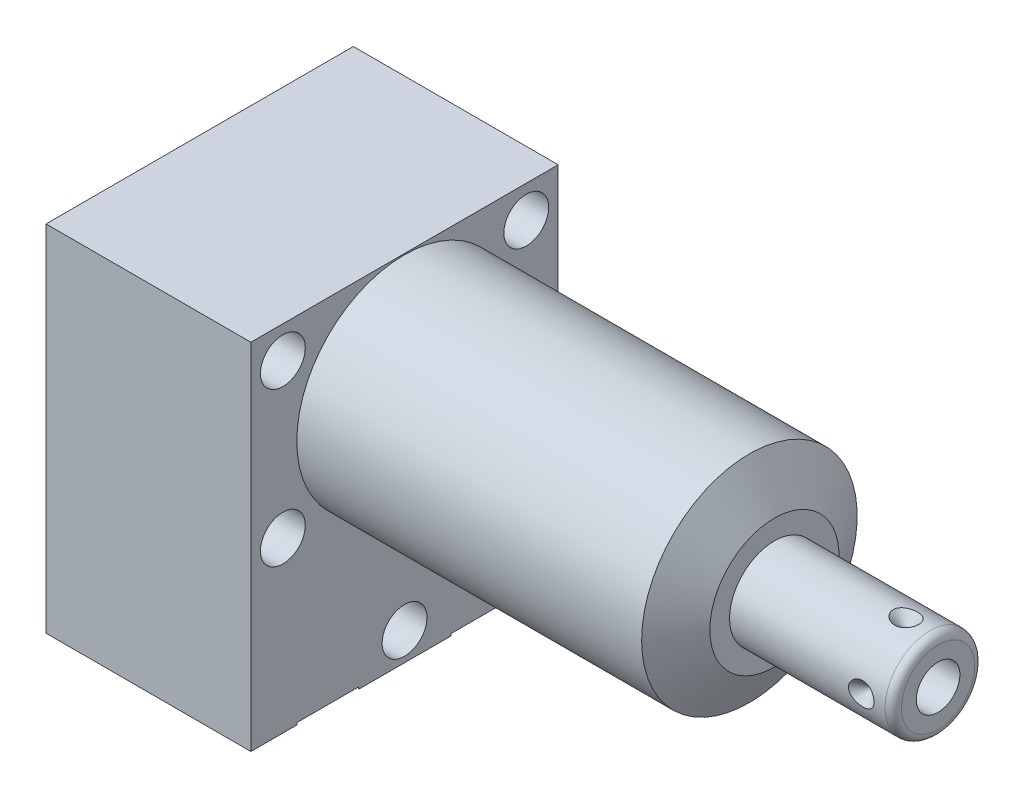
from build123d import *

# Parameters (mm, degrees)
SKETCH1_W           = 38.1
SKETCH1_H           = 43.942
EXTRUDE1_DEPTH      = 45.847
EXTRUDE1_DEPTH_BACK = 25.4
CUT_EXTRUDE1_REACH  = 47.847
SKETCH2_W           = 38.1
SKETCH2_H           = 43.942
SKETCH2_R           = 13.3604
SKETCH14_R          = 7.9375
CUT_EXTRUDE2_DEPTH  = 2.667
SKETCH10_R          = 6.4389
EXTRUDE2_DEPTH      = 1.651
SKETCH11_R          = 4.8006
EXTRUDE3_DEPTH      = 2.667
CIRPATTERN1_COUNT   = 4
HOLE1_D             = 5.5626
HOLE1_DEPTH         = 25.4


with BuildPart() as part:
    # Sketch1 → Extrude1 (new body, two sides)
    with BuildSketch(Plane(origin=(0, 0, 0), x_dir=(0, 0, -1), z_dir=(1, 0, 0))) as extrude1_sk:
        with Locations((0, -8.4836)):
            Rectangle(SKETCH1_W, SKETCH1_H)
    extrude(amount=EXTRUDE1_DEPTH)
    extrude(extrude1_sk.sketch, amount=-EXTRUDE1_DEPTH_BACK)

    # Sketch2 → Cut-Extrude1 (cut, up to next)
    with BuildSketch(Plane(origin=(0, 0, 0), x_dir=(0, 0, -1), z_dir=(1, 0, 0)), mode=Mode.PRIVATE) as cut_extrude1_sk1:
        with Locations((0, -8.4836)):
            Rectangle(SKETCH2_W, SKETCH2_H)
        Circle(SKETCH2_R, mode=Mode.SUBTRACT)
    cut_extrude1_tool1 = extrude(cut_extrude1_sk1.sketch, amount=CUT_EXTRUDE1_REACH, mode=Mode.PRIVATE) & part.part
    add(cut_extrude1_tool1.solids().sort_by_distance((0, 13.429241, 0))[0], mode=Mode.SUBTRACT)

    # Sketch3 → Cut-Revolve1 (revolve, cut)
    with BuildSketch(Plane.XY, mode=Mode.PRIVATE) as cut_revolve1_sk:
        Polygon((42.752748967, 13.3604), (45.847, 8.001), (45.847, 13.3604), align=None)
    revolve(cut_revolve1_sk.sketch.rotate(Axis((42.598036416, 0, 0), (1, 0, 0)), 90), axis=Axis((42.598036416, 0, 0), (1, 0, 0)), mode=Mode.SUBTRACT)  # turned: the seam where the file's is

    # S2D0002 → Cut-Revolve2 (revolve, cut)
    with BuildSketch(Plane(origin=(-22.733, -19.8374, 9.525), x_dir=(0, 1, 0), z_dir=(0, 0, 1)), mode=Mode.PRIVATE) as cut_revolve2_sk:
        Polygon((-0.8128, 0), (3.7338, 0), (3.293786662, -2.0701), (2.6416, -2.722286662), (2.6416, -13.97), (-0.8128, -13.97), align=None)
    revolve(cut_revolve2_sk.sketch.rotate(Axis((-8.0645, -20.6502, 9.525), (-1, 0, 0)), 90), axis=Axis((-8.0645, -20.6502, 9.525), (-1, 0, 0)), mode=Mode.SUBTRACT)  # turned: the seam where the file's is

    # Sketch5 → Cut-Revolve3 (revolve, cut)
    with BuildSketch(Plane(origin=(-22.733, -19.8374, -9.525), x_dir=(0, 1, 0), z_dir=(0, 0, 1)), mode=Mode.PRIVATE) as cut_revolve3_sk:
        Polygon((-0.8128, 0), (3.7338, 0), (3.293786662, -2.0701), (2.6416, -2.722286662), (2.6416, -13.97), (-0.8128, -13.97), align=None)
    revolve(cut_revolve3_sk.sketch.rotate(Axis((-8.0645, -20.6502, -9.525), (-1, 0, 0)), 90), axis=Axis((-8.0645, -20.6502, -9.525), (-1, 0, 0)), mode=Mode.SUBTRACT)  # turned: the seam where the file's is

    # Sketch14 → Cut-Extrude2 (cut)
    with BuildSketch(Plane.ZY.offset(25.4)):
        with Locations((-9.525, -20.6502)):
            Circle(SKETCH14_R)
        with Locations((9.525, -20.6502)):
            Circle(SKETCH14_R)
    extrude(amount=-CUT_EXTRUDE2_DEPTH, mode=Mode.SUBTRACT)

    # Sketch6 → Cut-Revolve4 (revolve, cut)
    with BuildSketch(Plane(origin=(-8.7376, -30.2006, 9.525), x_dir=(-1, 0, 0), z_dir=(0, 0, 1)), mode=Mode.PRIVATE) as cut_revolve4_sk:
        Polygon((6.18363, 0), (5.641036865, -2.5527), (4.97713, -3.216606865), (4.97713, -17.272), (0, -17.272), (0, 0), (0, 0.254), (9.52373, 0.254), (9.52373, 0), align=None)
    revolve(cut_revolve4_sk.sketch.rotate(Axis((-8.7376, -12.065, 9.525), (0, -1, 0)), 270), axis=Axis((-8.7376, -12.065, 9.525), (0, -1, 0)), mode=Mode.SUBTRACT)  # turned: the seam where the file's is

    # Sketch7 → Cut-Revolve5 (revolve, cut)
    with BuildSketch(Plane(origin=(-8.7376, -30.2006, -9.525), x_dir=(-1, 0, 0), z_dir=(0, 0, 1)), mode=Mode.PRIVATE) as cut_revolve5_sk:
        Polygon((6.1849, 0), (5.642306865, -2.5527), (4.9784, -3.216606865), (4.9784, -17.272), (0, -17.272), (0, 0), (0, 0.254), (9.52373, 0.254), (9.52373, 0), align=None)
    revolve(cut_revolve5_sk.sketch.rotate(Axis((-8.7376, -12.065, -9.525), (0, -1, 0)), 270), axis=Axis((-8.7376, -12.065, -9.525), (0, -1, 0)), mode=Mode.SUBTRACT)  # turned: the seam where the file's is

    # Sketch8 → Revolve1 (revolve)
    with BuildSketch(Plane.XY, mode=Mode.PRIVATE) as revolve1_sk:
        with BuildLine():
            Line((45.847, 0), (45.847, 5.55625))
            Line((45.847, 5.55625), (65.1256, 5.55625))
            ThreePointArc((65.1256, 5.55625), (65.84402049, 5.25867049), (66.1416, 4.54025))
            Line((66.1416, 4.54025), (66.1416, 0))
            Line((66.1416, 0), (45.847, 0))
        make_face()
    revolve(revolve1_sk.sketch.rotate(Axis((44.83227, 0, 0), (1, 0, 0)), 90), axis=Axis((44.83227, 0, 0), (1, 0, 0)))  # turned: the seam where the file's is

    # S2D0001 → Cut-Revolve6 (revolve, cut)
    with BuildSketch(Plane(origin=(66.1416, -2.8067, 0), x_dir=(0, -1, 0), z_dir=(0, 0, 1)), mode=Mode.PRIVATE) as cut_revolve6_sk:
        Polygon((-0.1016, 0), (-0.1016, -9.652), (-2.8067, -11.277388061), (-2.8067, 0), align=None)
    revolve(cut_revolve6_sk.sketch.rotate(Axis((53.702842726, 0, 0), (1, 0, 0)), 270), axis=Axis((53.702842726, 0, 0), (1, 0, 0)), mode=Mode.SUBTRACT)  # turned: the seam where the file's is

    # Sketch10 → Extrude2 (add)
    with BuildSketch(Plane(origin=(-25.4, -30.2006, 0), x_dir=(0, 0, -1), z_dir=(0, -1, 0))):
        with Locations(Location((-9.525, 16.6624, 0), (0, 0, 180))):  # turned: the seam where the file's is
            Circle(SKETCH10_R)
    extrude(amount=EXTRUDE2_DEPTH)

    # Sketch11 → Extrude3 (add)
    with BuildSketch(Plane.ZY.offset(22.733)):
        with Locations(Location((9.525, -20.6502, 0), (0, 0, 180))):  # turned: the seam where the file's is
            Circle(SKETCH11_R)
    extrude(amount=EXTRUDE3_DEPTH)

    # Sketch12 → Cut-Revolve7 (revolve, cut)
    with BuildSketch(Plane(origin=(62.1792, 5.55625, 0), x_dir=(-1, 0, 0), z_dir=(0, 0, -1)), mode=Mode.PRIVATE) as cut_revolve7_sk:
        Polygon((0, 0), (1.5875, 0), (0, -1.5875), align=None)
    cut_revolve7 = revolve(cut_revolve7_sk.sketch.rotate(Axis((62.1792, 2.12229387, 0), (0, 1, 0)), 90), axis=Axis((62.1792, 2.12229387, 0), (0, 1, 0)), mode=Mode.SUBTRACT)  # turned: the seam where the file's is

    # CirPattern1: Cut-Revolve7 ×4 about axis
    cirpattern1_axis = Axis((45.848, 0, 0), (-1, 0, 0))
    for i in range(1, CIRPATTERN1_COUNT):
        add(cut_revolve7.rotate(cirpattern1_axis, i * 360 / CIRPATTERN1_COUNT), mode=Mode.SUBTRACT)

    # Hole1
    with Locations(Plane(origin=(0, 0, 0), x_dir=(0, 0, -1), z_dir=(1, 0, 0))):
        with Locations((-15.0876, 9.525), (-15.0876, -9.525), (15.0876, 9.525), (15.0876, -9.525), (0, -26.9748)):
            Hole(HOLE1_D / 2, depth=HOLE1_DEPTH)


solid = part.part
